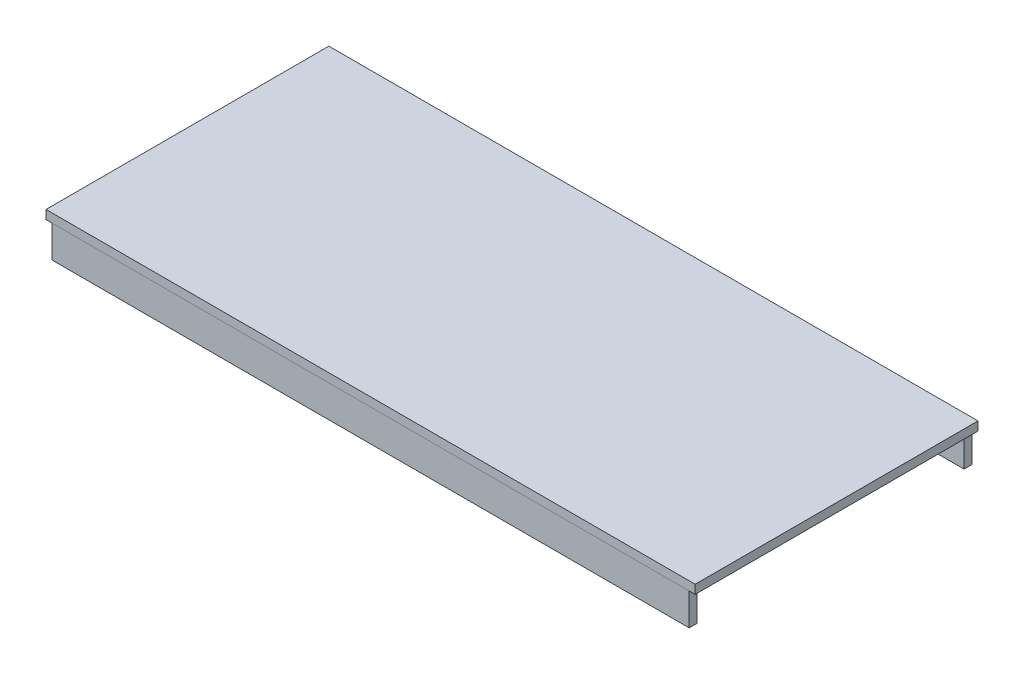
from build123d import *

# Parameters (mm, degrees)
SKETCH1_W             = 1400
SKETCH1_H             = 610
BOSS_EXTRUDE1_DEPTH   = 19
BOSS_EXTRUDE2_START   = -13
SKETCH2_W             = 17
SKETCH2_H             = 69
BOSS_EXTRUDE2_DEPTH   = 1374
BOSS_EXTRUDE2_2_DEPTH = 1374


with BuildPart() as part:
    # Sketch1 → Boss-Extrude1 (new body)
    with BuildSketch(Plane(origin=(0, 0, 0), x_dir=(1, 0, 0), z_dir=(0, 1, 0))):
        Rectangle(SKETCH1_W, SKETCH1_H)
    extrude(amount=-BOSS_EXTRUDE1_DEPTH)


with BuildPart() as body_2:
    # Sketch2 → Boss-Extrude2 (new body)
    with BuildSketch(Plane(origin=(700, 0, 0), x_dir=(0, 0, -1), z_dir=(1, 0, 0)).offset(BOSS_EXTRUDE2_START)):
        with Locations((-296.5, -53.5)):
            Rectangle(SKETCH2_W, SKETCH2_H)
    extrude(amount=-BOSS_EXTRUDE2_DEPTH)


with BuildPart() as body_3:
    # Sketch2 → Boss-Extrude2 2 (new body)
    with BuildSketch(Plane(origin=(700, 0, 0), x_dir=(0, 0, -1), z_dir=(1, 0, 0)).offset(BOSS_EXTRUDE2_START)):
        with Locations((296.5, -53.5)):
            Rectangle(SKETCH2_W, SKETCH2_H)
    extrude(amount=-BOSS_EXTRUDE2_2_DEPTH)


solid = Compound([part.part, body_2.part, body_3.part])
